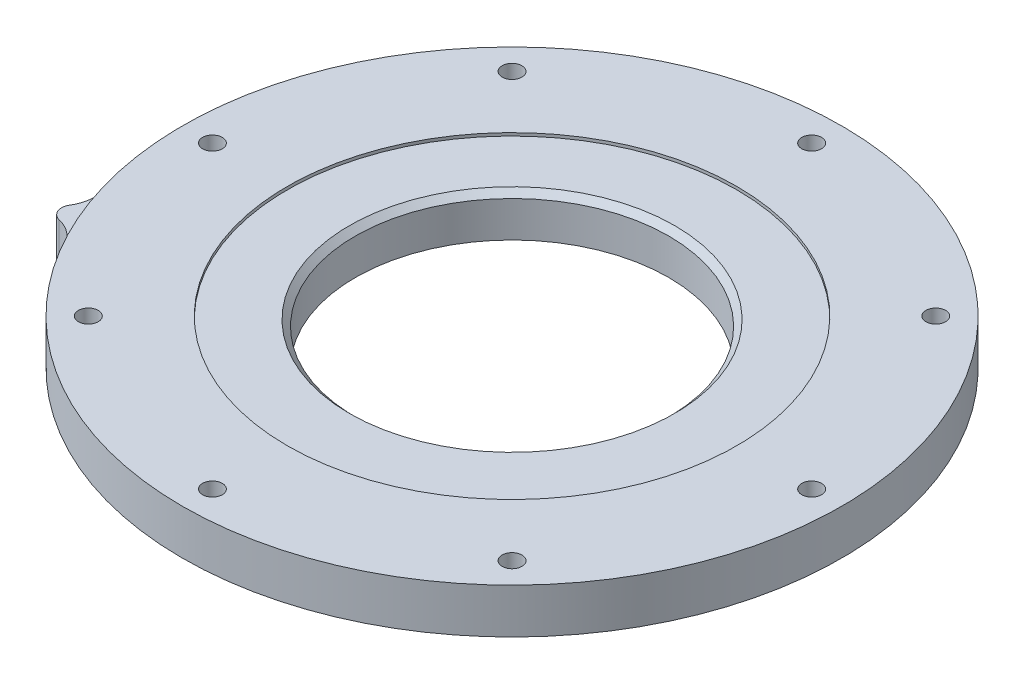
from build123d import *

# Parameters (mm, degrees)
SKETCH1_R           = 55
SKETCH1_R_2         = 37.5
SKETCH1_R_3         = 1.65
BOSS_EXTRUDE1_DEPTH = 0.5
SKETCH2_R           = 26.15
SKETCH2_R_2         = 1.65
BOSS_EXTRUDE2_DEPTH = 7
CHAMFER1_SIZE       = 1
SKETCH3_R           = 3.65
SKETCH3_R_2         = 1.65
CUT_EXTRUDE1_DEPTH  = 4


with BuildPart() as part:
    # Sketch1 → Boss-Extrude1 (new body)
    with BuildSketch(Plane(origin=(0, 0, 0), x_dir=(1, 0, 0), z_dir=(0, 1, 0))):
        Circle(SKETCH1_R)
        Circle(SKETCH1_R_2, mode=Mode.SUBTRACT)
        with Locations((0, 50)):
            Circle(SKETCH1_R_3, mode=Mode.SUBTRACT)
        with Locations((35.355339059, 35.355339059)):
            Circle(SKETCH1_R_3, mode=Mode.SUBTRACT)
        with Locations((50, 0)):
            Circle(SKETCH1_R_3, mode=Mode.SUBTRACT)
        with Locations((35.355339059, -35.355339059)):
            Circle(SKETCH1_R_3, mode=Mode.SUBTRACT)
        with Locations((0, -50)):
            Circle(SKETCH1_R_3, mode=Mode.SUBTRACT)
        with Locations((-35.355339059, -35.355339059)):
            Circle(SKETCH1_R_3, mode=Mode.SUBTRACT)
        with Locations((-50, 0)):
            Circle(SKETCH1_R_3, mode=Mode.SUBTRACT)
        with Locations((-35.355339059, 35.355339059)):
            Circle(SKETCH1_R_3, mode=Mode.SUBTRACT)
    extrude(amount=BOSS_EXTRUDE1_DEPTH)

    # Sketch2 → Boss-Extrude2 (add)
    with BuildSketch(Plane.XZ):
        with BuildLine():
            ThreePointArc((-52.76902678, 15.505799326), (50.813374288, -21.04758878), (-48.277592523, 26.349080822))
            ThreePointArc((-48.277592523, 26.349080822), (-49.915423513, 24.445273361), (-52.189000111, 23.37858566))
            ThreePointArc((-52.189000111, 23.37858566), (-53.585012886, 22.195639077), (-53.434352336, 20.372039427))
            ThreePointArc((-53.434352336, 20.372039427), (-52.580953013, 18.01011589), (-52.76902678, 15.505799326))
        make_face()
        Circle(SKETCH2_R, mode=Mode.SUBTRACT)
        with Locations((0, -50)):
            Circle(SKETCH2_R_2, mode=Mode.SUBTRACT)
        with Locations((35.355339059, -35.355339059)):
            Circle(SKETCH2_R_2, mode=Mode.SUBTRACT)
        with Locations((50, 0)):
            Circle(SKETCH2_R_2, mode=Mode.SUBTRACT)
        with Locations((35.355339059, 35.355339059)):
            Circle(SKETCH2_R_2, mode=Mode.SUBTRACT)
        with Locations((0, 50)):
            Circle(SKETCH2_R_2, mode=Mode.SUBTRACT)
        with Locations((-35.355339059, 35.355339059)):
            Circle(SKETCH2_R_2, mode=Mode.SUBTRACT)
        with Locations((-50, 0)):
            Circle(SKETCH2_R_2, mode=Mode.SUBTRACT)
        with Locations((-35.355339059, -35.355339059)):
            Circle(SKETCH2_R_2, mode=Mode.SUBTRACT)
    extrude(amount=BOSS_EXTRUDE2_DEPTH)

    # Chamfer1
    chamfer1_edges = [part.edges().sort_by_distance(p)[0] for p in [
        (-26.15, 0, 0),
    ]]
    chamfer(chamfer1_edges, length=CHAMFER1_SIZE)

    # Sketch3 → Cut-Extrude1 (cut)
    with BuildSketch(Plane.XZ.offset(7)):
        with Locations((-50, 0)):
            Circle(SKETCH3_R)
        with Locations((-50, 0)):
            Circle(SKETCH3_R_2, mode=Mode.SUBTRACT)
        with Locations((-35.355339059, -35.355339059)):
            Circle(SKETCH3_R)
        with Locations((-35.355339059, -35.355339059)):
            Circle(SKETCH3_R_2, mode=Mode.SUBTRACT)
        with Locations((0, -50)):
            Circle(SKETCH3_R)
        with Locations((0, -50)):
            Circle(SKETCH3_R_2, mode=Mode.SUBTRACT)
        with Locations((35.355339059, -35.355339059)):
            Circle(SKETCH3_R)
        with Locations((35.355339059, -35.355339059)):
            Circle(SKETCH3_R_2, mode=Mode.SUBTRACT)
        with Locations((50, 0)):
            Circle(SKETCH3_R)
        with Locations((50, 0)):
            Circle(SKETCH3_R_2, mode=Mode.SUBTRACT)
        with Locations((35.355339059, 35.355339059)):
            Circle(SKETCH3_R)
        with Locations((35.355339059, 35.355339059)):
            Circle(SKETCH3_R_2, mode=Mode.SUBTRACT)
        with Locations((0, 50)):
            Circle(SKETCH3_R)
        with Locations((0, 50)):
            Circle(SKETCH3_R_2, mode=Mode.SUBTRACT)
        with Locations((-35.355339059, 35.355339059)):
            Circle(SKETCH3_R)
        with Locations((-35.355339059, 35.355339059)):
            Circle(SKETCH3_R_2, mode=Mode.SUBTRACT)
    extrude(amount=-CUT_EXTRUDE1_DEPTH, mode=Mode.SUBTRACT)


solid = part.part
